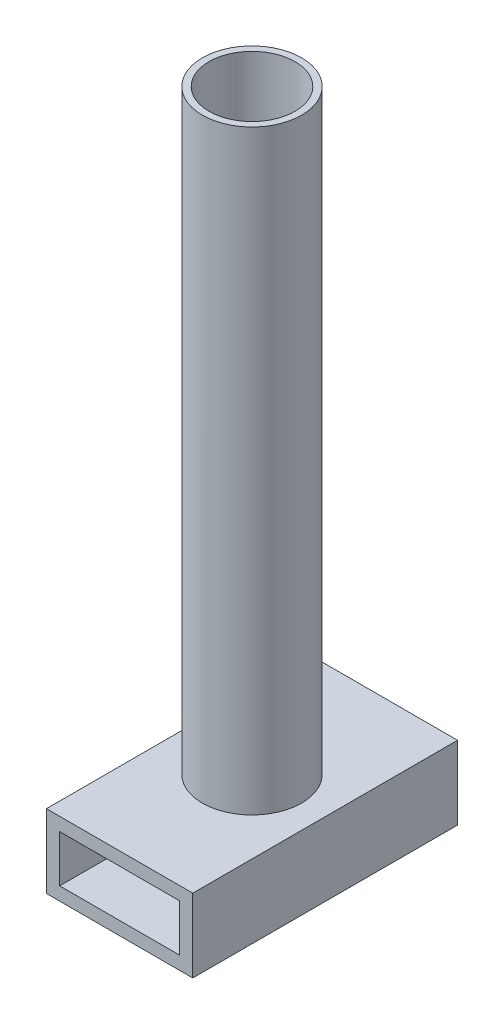
from build123d import *

# Parameters (mm, degrees)
SKETCH1_W           = 22.1
SKETCH1_H           = 11.1
SKETCH1_W_2         = 18.1
SKETCH1_H_2         = 7.1
BOSS_EXTRUDE1_DEPTH = 40
SKETCH2_R           = 1.5
CUT_EXTRUDE1_DEPTH  = 33
SKETCH3_R           = 7.5
SKETCH3_R_2         = 6.5
BOSS_EXTRUDE3_DEPTH = 90


with BuildPart() as part:
    # Sketch1 → Boss-Extrude1 (new body)
    with BuildSketch(Plane.XY):
        Rectangle(SKETCH1_W, SKETCH1_H)
        Rectangle(SKETCH1_W_2, SKETCH1_H_2, mode=Mode.SUBTRACT)
    extrude(amount=BOSS_EXTRUDE1_DEPTH)

    # Sketch2 → Cut-Extrude1 (cut)
    with BuildSketch(Plane.XZ.offset(5.55)):
        with Locations((0, 20)):
            Circle(SKETCH2_R)
    extrude(amount=-CUT_EXTRUDE1_DEPTH, mode=Mode.SUBTRACT)

    # Sketch3 → Boss-Extrude3 (add)
    with BuildSketch(Plane(origin=(0, 5.55, 0), x_dir=(1, 0, 0), z_dir=(0, 1, 0))):
        with Locations((0, -20)):
            Circle(SKETCH3_R)
        with Locations((0, -20)):
            Circle(SKETCH3_R_2, mode=Mode.SUBTRACT)
    extrude(amount=BOSS_EXTRUDE3_DEPTH)


solid = part.part
